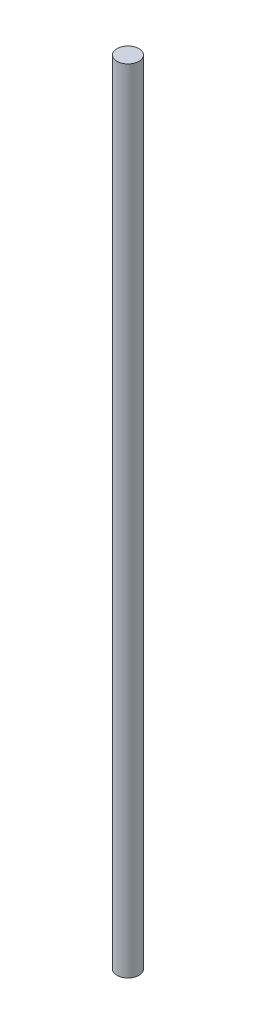
from build123d import *

# Parameters (mm, degrees)
SKETCH1_R           = 3.175
BOSS_EXTRUDE1_DEPTH = 228.6


with BuildPart() as part:
    # Sketch1 → Boss-Extrude1 (new body)
    with BuildSketch(Plane(origin=(0, 0, 0), x_dir=(1, 0, 0), z_dir=(0, 1, 0))):
        Circle(SKETCH1_R)
    extrude(amount=BOSS_EXTRUDE1_DEPTH)


solid = part.part
